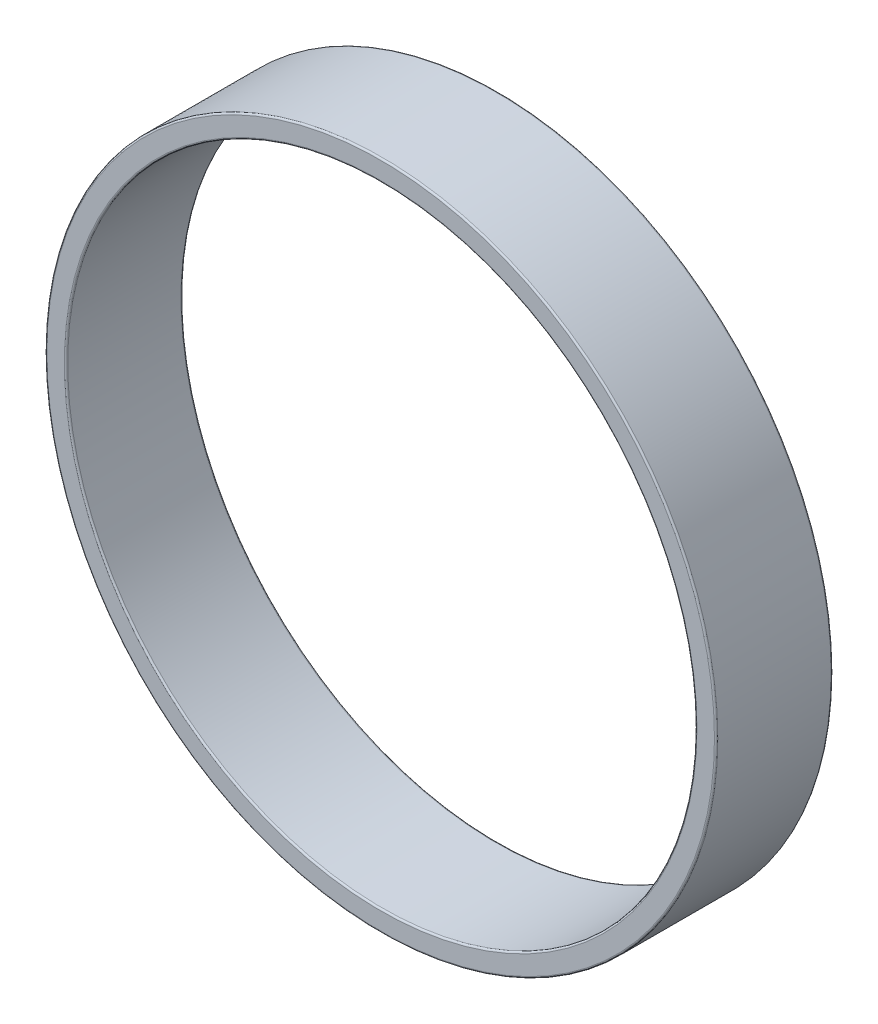
from build123d import *

# Parameters (mm, degrees)
SKETCH2_R           = 80.5
SKETCH2_R_2         = 75.5
BOSS_EXTRUDE1_DEPTH = 28
FILLET1_R           = 0.4


with BuildPart() as part:
    # Sketch2 → Boss-Extrude1 (new body)
    with BuildSketch(Plane.XY):
        Circle(SKETCH2_R)
        Circle(SKETCH2_R_2, mode=Mode.SUBTRACT)
    extrude(amount=BOSS_EXTRUDE1_DEPTH)

    # Fillet1
    fillet1_edges = [part.edges().sort_by_distance(p)[0] for p in [
        (-80.5, 0, 0),
        (-80.5, 0, 28),
        (-75.5, 0, 0),
        (-75.5, 0, 28),
    ]]
    fillet(fillet1_edges, radius=FILLET1_R)


solid = part.part
